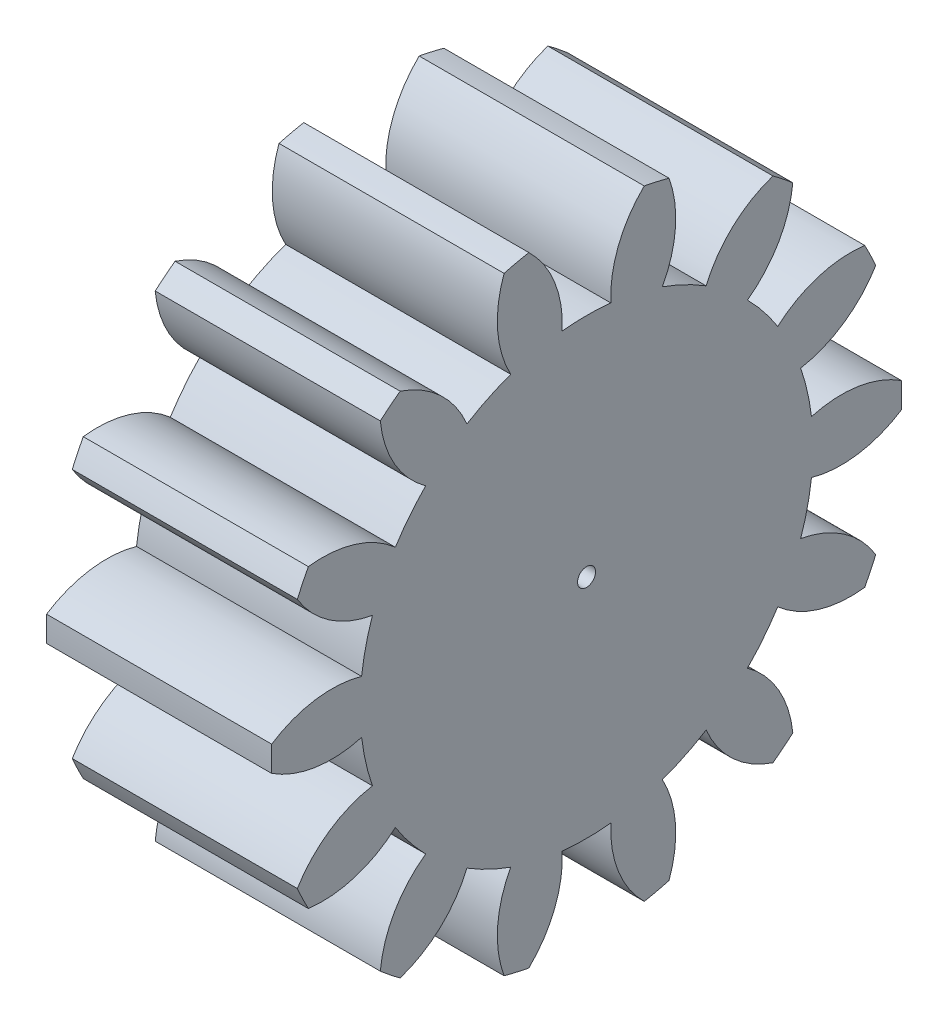
from build123d import *

# Parameters (mm, degrees)
BASPROSKE_W     = 10
BASPROSKE_H     = 14
TOOTHCUT_DEPTH  = 23.181073013
TEETHCUTS_COUNT = 14
TEETHCUTS_ANGLE = 334.285714286
BORSKE_R        = 0.4
BORE_DEPTH      = 50.0000508


with BuildPart() as part:
    # BasProSke → Base-Revolve (revolve)
    with BuildSketch(Plane(origin=(0, 0, 0), x_dir=(1, 0, 0), z_dir=(0, 1, 0)), mode=Mode.PRIVATE) as base_revolve_sk:
        with Locations((5, 7)):
            Rectangle(BASPROSKE_W, BASPROSKE_H)
    revolve(base_revolve_sk.sketch.rotate(Axis((-10, 0, 0), (1, 0, 0)), 180), axis=Axis((-10, 0, 0), (1, 0, 0)))

    # TooCutSke → ToothCut (cut, through all)
    with BuildSketch(Plane(origin=(0, 0, 0), x_dir=(0, 0, -1), z_dir=(1, 0, 0))):
        with BuildLine():
            ThreePointArc((1.07977267, 10.003393086), (0, 10.0615), (-1.07977267, 10.003393086))
            ThreePointArc((-1.07977267, 10.003393086), (-1.421345253, 12.057954139), (-2.585409426, 13.785046364))
            ThreePointArc((-2.585409426, 13.785046364), (0, 14.0254), (2.585409426, 13.785046364))
            ThreePointArc((2.585409426, 13.785046364), (1.421345253, 12.057954139), (1.07977267, 10.003393086))
        make_face()
    toothcut = extrude(amount=TOOTHCUT_DEPTH, mode=Mode.SUBTRACT)

    # TeethCuts: ToothCut ×14 about axis
    teethcuts_axis = Axis((-10, 0, 0), (1, 0, 0))
    for i in range(1, TEETHCUTS_COUNT):
        add(toothcut.rotate(teethcuts_axis, i * TEETHCUTS_ANGLE / (TEETHCUTS_COUNT - 1)), mode=Mode.SUBTRACT)

    # BorSke → Bore (cut, symmetric)
    with BuildSketch(Plane(origin=(0, 0, 0), x_dir=(0, 0, -1), z_dir=(1, 0, 0))):
        with Locations(Location((0, 0, 0), (0, 0, 180))):
            Circle(BORSKE_R)
    extrude(amount=BORE_DEPTH, both=True, mode=Mode.SUBTRACT)


solid = part.part
